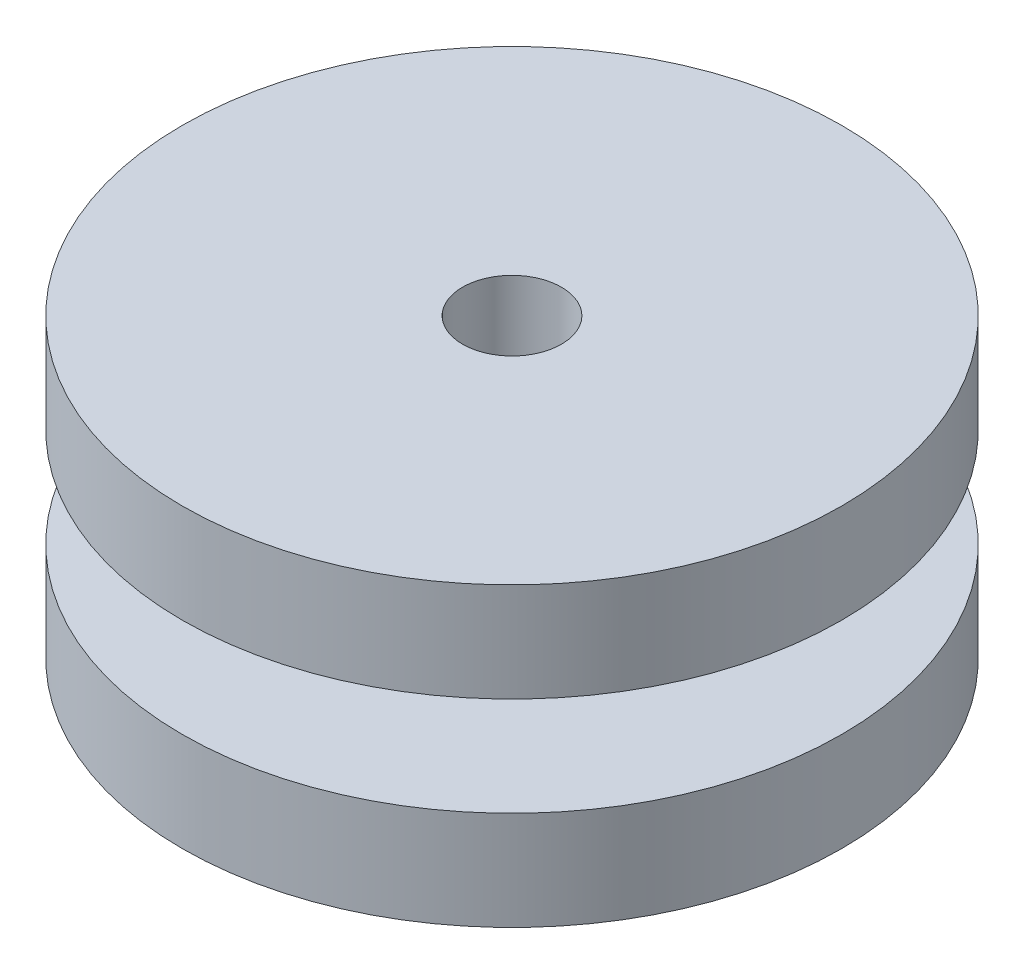
from build123d import *

# Parameters (mm, degrees)
SKETCH1_R           = 3.5
SKETCH1_R_2         = 1.5
BOSS_EXTRUDE1_DEPTH = 9
SKETCH2_R           = 6
SKETCH2_R_2         = 1.5
BOSS_EXTRUDE2_DEPTH = 3
SKETCH3_R           = 5
SKETCH3_R_2         = 1.5
BOSS_EXTRUDE3_DEPTH = 3
FILLET2_R           = 1
SKETCH4_R           = 10
SKETCH4_R_2         = 1.5
BOSS_EXTRUDE4_DEPTH = 3
SKETCH5_R           = 10
SKETCH5_R_2         = 1.5
BOSS_EXTRUDE5_DEPTH = 3


with BuildPart() as part:
    # Sketch1 → Boss-Extrude1 (new body)
    with BuildSketch(Plane(origin=(0, 0, 0), x_dir=(1, 0, 0), z_dir=(0, 1, 0))):
        Circle(SKETCH1_R)
        Circle(SKETCH1_R_2, mode=Mode.SUBTRACT)
    extrude(amount=BOSS_EXTRUDE1_DEPTH)

    # Sketch2 → Boss-Extrude2 (add)
    with BuildSketch(Plane(origin=(0, 9, 0), x_dir=(1, 0, 0), z_dir=(0, 1, 0))):
        Circle(SKETCH2_R)
        Circle(SKETCH2_R_2, mode=Mode.SUBTRACT)
    extrude(amount=-BOSS_EXTRUDE2_DEPTH)

    # Sketch3 → Boss-Extrude3 (add)
    with BuildSketch(Plane.XZ):
        Circle(SKETCH3_R)
        Circle(SKETCH3_R_2, mode=Mode.SUBTRACT)
    extrude(amount=-BOSS_EXTRUDE3_DEPTH)

    # Fillet2
    fillet2_edges = [part.edges().sort_by_distance(p)[0] for p in [
        (-3.5, 6, 0),
        (-3.5, 3, 0),
    ]]
    fillet(fillet2_edges, radius=FILLET2_R)

    # Sketch4 → Boss-Extrude4 (add)
    with BuildSketch(Plane.XZ):
        Circle(SKETCH4_R)
        Circle(SKETCH4_R_2, mode=Mode.SUBTRACT)
    extrude(amount=-BOSS_EXTRUDE4_DEPTH)

    # Sketch5 → Boss-Extrude5 (add)
    with BuildSketch(Plane(origin=(0, 9, 0), x_dir=(1, 0, 0), z_dir=(0, 1, 0))):
        Circle(SKETCH5_R)
        Circle(SKETCH5_R_2, mode=Mode.SUBTRACT)
    extrude(amount=-BOSS_EXTRUDE5_DEPTH)


solid = part.part
